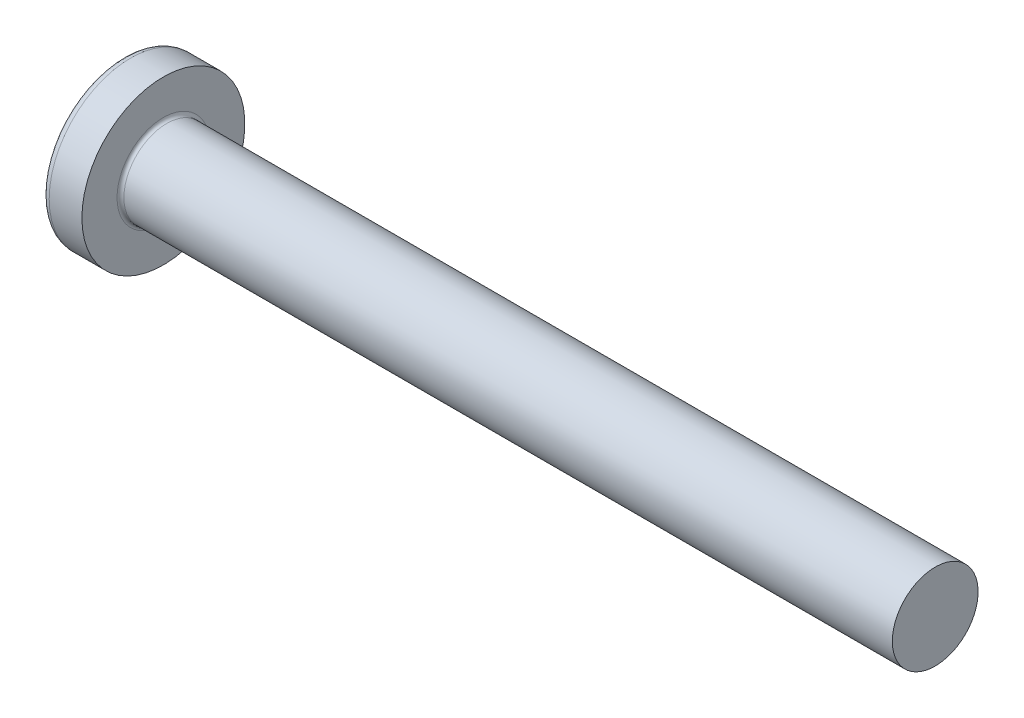
from build123d import *

# Parameters (mm, degrees)
FILLET1_R    = 0.2
SKETCH3_W    = 1.03
SKETCH3_H    = 4.7
SKETCH4_W    = 1.03
SKETCH4_H    = 1.967772882
RECPAT_COUNT = 2
RECPAT_ANGLE = 90


with BuildPart() as part:
    # BodySke → Base-Revolve (revolve)
    with BuildSketch(Plane.XY, mode=Mode.PRIVATE) as base_revolve_sk:
        with BuildLine():
            Line((3.7, 2.5), (3.7, 4.75))
            Line((3.7, 4.75), (1.79415598, 4.75))
            ThreePointArc((1.79415598, 4.75), (1.58538712, 4.698642149), (1.424271237, 4.556291391))
            ThreePointArc((1.424271237, 4.556291391), (0.364365445, 2.386856709), (0, 0))
            Line((0, 0), (48.7, 0))
            Line((48.7, 0), (48.7, 2.5))
            Line((48.7, 2.5), (3.7, 2.5))
        make_face()
    revolve(base_revolve_sk.sketch.rotate(Axis((-25.4, 0, 0), (1, 0, 0)), 90), axis=Axis((-25.4, 0, 0), (1, 0, 0)))  # turned: the seam where the file's is

    # Fillet1
    fillet1_edges = [part.edges().sort_by_distance(p)[0] for p in [
        (3.7, 0, -2.5),
    ]]
    fillet(fillet1_edges, radius=FILLET1_R)

    # Sketch3 → Recess section 0
    with BuildSketch(Plane(origin=(0, 0, 0), x_dir=(0, 0, -1), z_dir=(1, 0, 0))):
        Rectangle(SKETCH3_W, SKETCH3_H)
    # Sketch4 → Recess section 1
    with BuildSketch(Plane(origin=(2.74, 0, 0), x_dir=(0, 0, -1), z_dir=(1, 0, 0))):
        Rectangle(SKETCH4_W, SKETCH4_H)
    recess = loft(mode=Mode.SUBTRACT)

    # RecPat: Recess ×2 about axis
    recpat_axis = Axis((0, 0, 0), (1, 0, 0))
    for i in range(1, RECPAT_COUNT):
        add(recess.rotate(recpat_axis, i * RECPAT_ANGLE / (RECPAT_COUNT - 1)), mode=Mode.SUBTRACT)

    # RecCorSke → RecessCore (revolve, cut)
    with BuildSketch(Plane.XY, mode=Mode.PRIVATE) as recesscore_sk:
        Polygon((0, 0), (0, 1.042599465), (2.74, 0.851), (3.016506661, 0), align=None)
    revolve(recesscore_sk.sketch.rotate(Axis((-3.175, 0, 0), (1, 0, 0)), 90), axis=Axis((-3.175, 0, 0), (1, 0, 0)), mode=Mode.SUBTRACT)  # turned: the seam where the file's is


solid = part.part
